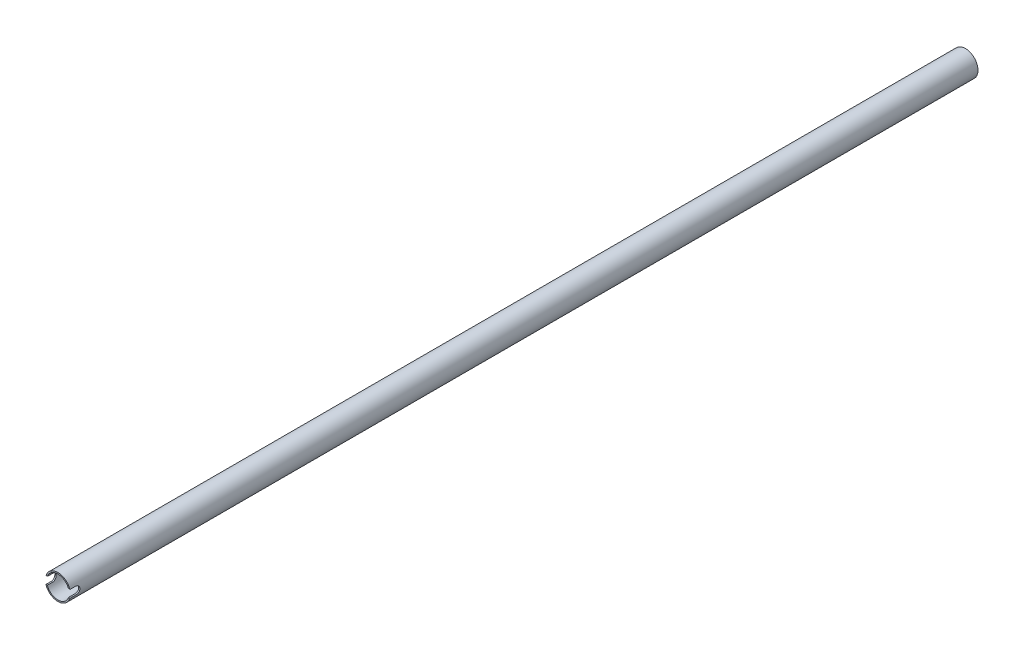
from build123d import *

# Parameters (mm, degrees)
SKETCH4_R           = 33
SKETCH4_R_2         = 29.5
BOSS_EXTRUDE1_DEPTH = 2380
CUT_EXTRUDE1_DEPTH  = 67
FILLET1_R           = 1


with BuildPart() as part:
    # Sketch4 → Boss-Extrude1 (new body)
    with BuildSketch(Plane.XY):
        with Locations((33, 0)):
            Circle(SKETCH4_R)
        with Locations((33, 0)):
            Circle(SKETCH4_R_2, mode=Mode.SUBTRACT)
    extrude(amount=-BOSS_EXTRUDE1_DEPTH)

    # Sketch6 → Cut-Extrude1 (cut, through all)
    with BuildSketch(Plane(origin=(0, 0, 0), x_dir=(0, 0, -1), z_dir=(1, 0, 0))):
        with BuildLine():
            Line((0, 10), (0, -10))
            Line((0, -10), (15, -10))
            ThreePointArc((15, -10), (25, 0), (15, 10))
            Line((15, 10), (0, 10))
        make_face()
    extrude(amount=CUT_EXTRUDE1_DEPTH, mode=Mode.SUBTRACT)

    # Fillet1
    fillet1_edges = [part.edges().sort_by_distance(p)[0] for p in [
        (3.39912572, 10, 0),
        (62.60087428, 10, 0),
        (3.39912572, -10, 0),
        (62.60087428, -10, 0),
    ]]
    fillet(fillet1_edges, radius=FILLET1_R)


solid = part.part
